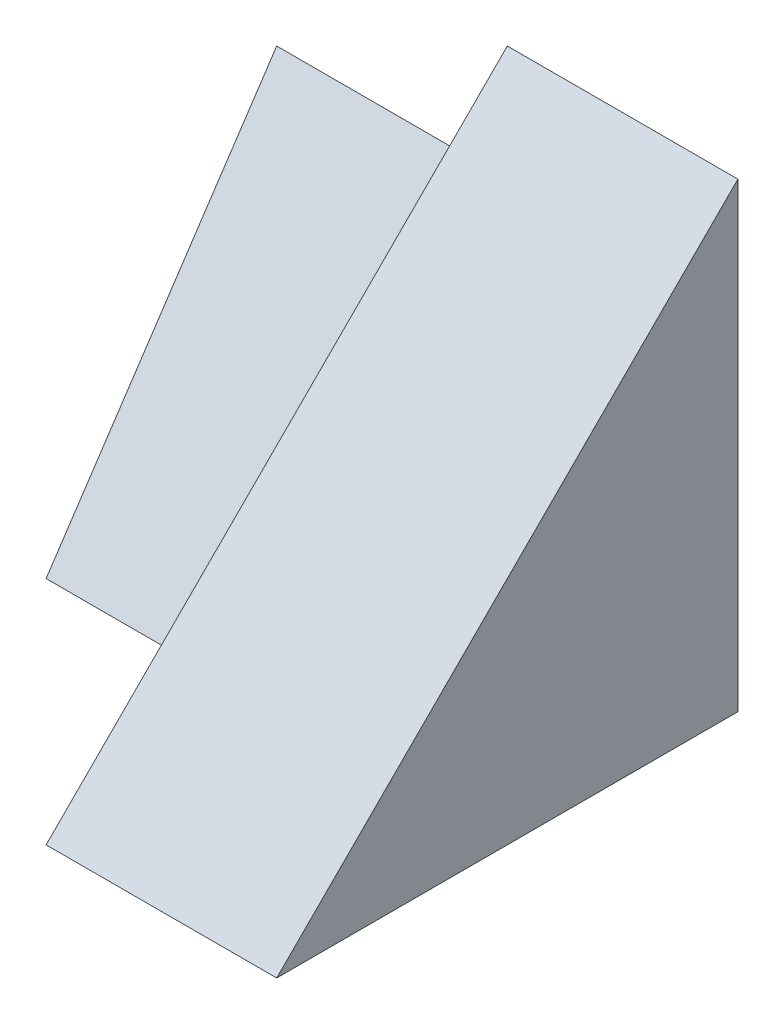
from build123d import *

# Parameters (mm, degrees)
SKETCH1_W           = 4
SKETCH1_H           = 4
BOSS_EXTRUDE1_DEPTH = 2
SKETCH2_W           = 2
SKETCH2_H           = 3
BOSS_EXTRUDE2_DEPTH = 2
CUT_EXTRUDE1_DEPTH  = 2
CUT_EXTRUDE2_DEPTH  = 2


with BuildPart() as part:
    # Sketch1 → Boss-Extrude1 (new body)
    with BuildSketch(Plane(origin=(0, 0, 0), x_dir=(0, 0, -1), z_dir=(1, 0, 0))):
        with Locations((2, 2)):
            Rectangle(SKETCH1_W, SKETCH1_H)
    extrude(amount=BOSS_EXTRUDE1_DEPTH)

    # Sketch2 → Boss-Extrude2 (add)
    with BuildSketch(Plane.ZY):
        with Locations((-3, 1.5)):
            Rectangle(SKETCH2_W, SKETCH2_H)
    extrude(amount=BOSS_EXTRUDE2_DEPTH)

    # Sketch3 → Cut-Extrude1 (cut)
    with BuildSketch(Plane.ZY.offset(2)):
        Polygon((-4, 3), (-2, 3), (-2, 0), align=None)
    extrude(amount=-CUT_EXTRUDE1_DEPTH, mode=Mode.SUBTRACT)

    # Sketch4 → Cut-Extrude2 (cut)
    with BuildSketch(Plane(origin=(2, 0, 0), x_dir=(0, 0, -1), z_dir=(1, 0, 0))):
        Polygon((4, 4), (0, 0), (0, 4), align=None)
    extrude(amount=-CUT_EXTRUDE2_DEPTH, mode=Mode.SUBTRACT)


solid = part.part
